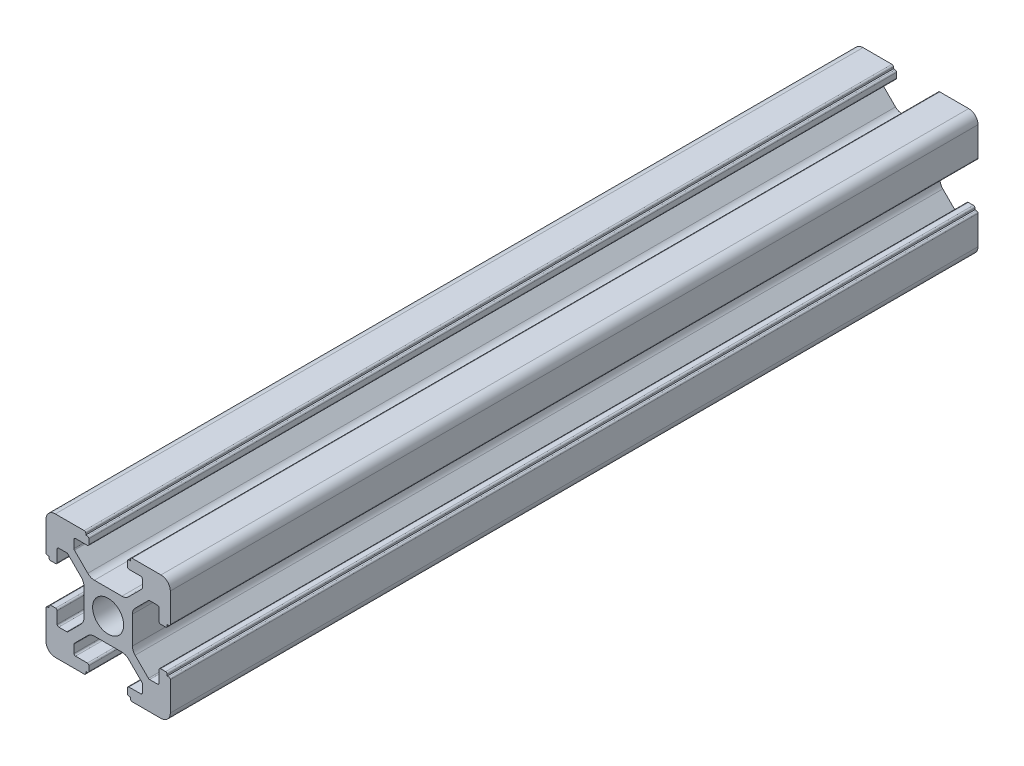
from build123d import *

# Parameters (mm, degrees)
SKETCH_1_R      = 2.5
EXTRUDE_1_DEPTH = 130


with BuildPart() as part:
    # 草图1 → 凸台-拉伸1 (new body)
    with BuildSketch(Plane.XY):
        with BuildLine():
            Line((-8.502261885, -10.002261885), (-3.85, -10.002261885))
            ThreePointArc((-3.85, -10.002261885), (-3.673223305, -9.929038581), (-3.6, -9.752261885))
            Line((-3.6, -9.752261885), (-3.6, -9.502261885))
            Line((-3.6, -9.502261885), (-3.35, -9.502261885))
            ThreePointArc((-3.35, -9.502261885), (-3.173223305, -9.429038581), (-3.1, -9.252261885))
            Line((-3.1, -9.252261885), (-3.1, -8.45))
            ThreePointArc((-3.1, -8.45), (-3.173223305, -8.273223305), (-3.35, -8.2))
            Line((-3.35, -8.2), (-5.25, -8.2))
            ThreePointArc((-5.25, -8.2), (-5.426776695, -8.126776695), (-5.5, -7.95))
            Line((-5.5, -7.95), (-5.5, -6.664213562))
            ThreePointArc((-5.5, -6.664213562), (-5.480969883, -6.568542704), (-5.426776695, -6.487436867))
            Line((-5.426776695, -6.487436867), (-3.278679656, -4.339339828))
            ThreePointArc((-3.278679656, -4.339339828), (-2.792044633, -4.014180701), (-2.218019485, -3.9))
            Line((-2.218019485, -3.9), (2.218019485, -3.9))
            ThreePointArc((2.218019485, -3.9), (2.792044633, -4.014180701), (3.278679656, -4.339339828))
            Line((3.278679656, -4.339339828), (5.426776695, -6.487436867))
            ThreePointArc((5.426776695, -6.487436867), (5.480969883, -6.568542704), (5.5, -6.664213562))
            Line((5.5, -6.664213562), (5.5, -7.95))
            ThreePointArc((5.5, -7.95), (5.426776695, -8.126776695), (5.25, -8.2))
            Line((5.25, -8.2), (3.35, -8.2))
            ThreePointArc((3.35, -8.2), (3.173223305, -8.273223305), (3.1, -8.45))
            Line((3.1, -8.45), (3.1, -9.252261885))
            ThreePointArc((3.1, -9.252261885), (3.173223305, -9.429038581), (3.35, -9.502261885))
            Line((3.35, -9.502261885), (3.6, -9.502261885))
            Line((3.6, -9.502261885), (3.6, -9.752261885))
            ThreePointArc((3.6, -9.752261885), (3.673223305, -9.929038581), (3.85, -10.002261885))
            Line((3.85, -10.002261885), (8.502261885, -10.002261885))
            ThreePointArc((8.502261885, -10.002261885), (9.562922057, -9.562922057), (10.002261885, -8.502261885))
            Line((10.002261885, -8.502261885), (10.002261885, -3.85))
            ThreePointArc((10.002261885, -3.85), (9.929038581, -3.673223305), (9.752261885, -3.6))
            Line((9.752261885, -3.6), (9.502261885, -3.6))
            Line((9.502261885, -3.6), (9.502261885, -3.35))
            ThreePointArc((9.502261885, -3.35), (9.429038581, -3.173223305), (9.252261885, -3.1))
            Line((9.252261885, -3.1), (8.45, -3.1))
            ThreePointArc((8.45, -3.1), (8.273223305, -3.173223305), (8.2, -3.35))
            Line((8.2, -3.35), (8.2, -5.25))
            ThreePointArc((8.2, -5.25), (8.126776695, -5.426776695), (7.95, -5.5))
            Line((7.95, -5.5), (6.664213562, -5.5))
            ThreePointArc((6.664213562, -5.5), (6.568542704, -5.480969883), (6.487436867, -5.426776695))
            Line((6.487436867, -5.426776695), (4.339339828, -3.278679656))
            ThreePointArc((4.339339828, -3.278679656), (4.014180701, -2.792044633), (3.9, -2.218019485))
            Line((3.9, -2.218019485), (3.9, 2.218019485))
            ThreePointArc((3.9, 2.218019485), (4.014180701, 2.792044633), (4.339339828, 3.278679656))
            Line((4.339339828, 3.278679656), (6.487436867, 5.426776695))
            ThreePointArc((6.487436867, 5.426776695), (6.568542704, 5.480969883), (6.664213562, 5.5))
            Line((6.664213562, 5.5), (7.95, 5.5))
            ThreePointArc((7.95, 5.5), (8.126776695, 5.426776695), (8.2, 5.25))
            Line((8.2, 5.25), (8.2, 3.35))
            ThreePointArc((8.2, 3.35), (8.273223305, 3.173223305), (8.45, 3.1))
            Line((8.45, 3.1), (9.252261885, 3.1))
            ThreePointArc((9.252261885, 3.1), (9.429038581, 3.173223305), (9.502261885, 3.35))
            Line((9.502261885, 3.35), (9.502261885, 3.6))
            Line((9.502261885, 3.6), (9.752261885, 3.6))
            ThreePointArc((9.752261885, 3.6), (9.929038581, 3.673223305), (10.002261885, 3.85))
            Line((10.002261885, 3.85), (10.002261885, 8.502261885))
            ThreePointArc((10.002261885, 8.502261885), (9.562922057, 9.562922057), (8.502261885, 10.002261885))
            Line((8.502261885, 10.002261885), (3.85, 10.002261885))
            ThreePointArc((3.85, 10.002261885), (3.673223305, 9.929038581), (3.6, 9.752261885))
            Line((3.6, 9.752261885), (3.6, 9.502261885))
            Line((3.6, 9.502261885), (3.35, 9.502261885))
            ThreePointArc((3.35, 9.502261885), (3.173223305, 9.429038581), (3.1, 9.252261885))
            Line((3.1, 9.252261885), (3.1, 8.45))
            ThreePointArc((3.1, 8.45), (3.173223305, 8.273223305), (3.35, 8.2))
            Line((3.35, 8.2), (5.25, 8.2))
            ThreePointArc((5.25, 8.2), (5.426776695, 8.126776695), (5.5, 7.95))
            Line((5.5, 7.95), (5.5, 6.664213562))
            ThreePointArc((5.5, 6.664213562), (5.480969883, 6.568542704), (5.426776695, 6.487436867))
            Line((5.426776695, 6.487436867), (3.278679656, 4.339339828))
            ThreePointArc((3.278679656, 4.339339828), (2.792044633, 4.014180701), (2.218019485, 3.9))
            Line((2.218019485, 3.9), (-2.218019485, 3.9))
            ThreePointArc((-2.218019485, 3.9), (-2.792044633, 4.014180701), (-3.278679656, 4.339339828))
            Line((-3.278679656, 4.339339828), (-5.426776695, 6.487436867))
            ThreePointArc((-5.426776695, 6.487436867), (-5.480969883, 6.568542704), (-5.5, 6.664213562))
            Line((-5.5, 6.664213562), (-5.5, 7.95))
            ThreePointArc((-5.5, 7.95), (-5.426776695, 8.126776695), (-5.25, 8.2))
            Line((-5.25, 8.2), (-3.35, 8.2))
            ThreePointArc((-3.35, 8.2), (-3.173223305, 8.273223305), (-3.1, 8.45))
            Line((-3.1, 8.45), (-3.1, 9.252261885))
            ThreePointArc((-3.1, 9.252261885), (-3.173223305, 9.429038581), (-3.35, 9.502261885))
            Line((-3.35, 9.502261885), (-3.6, 9.502261885))
            Line((-3.6, 9.502261885), (-3.6, 9.752261885))
            ThreePointArc((-3.6, 9.752261885), (-3.673223305, 9.929038581), (-3.85, 10.002261885))
            Line((-3.85, 10.002261885), (-8.502261885, 10.002261885))
            ThreePointArc((-8.502261885, 10.002261885), (-9.562922057, 9.562922057), (-10.002261885, 8.502261885))
            Line((-10.002261885, 8.502261885), (-10.002261885, 3.85))
            ThreePointArc((-10.002261885, 3.85), (-9.929038581, 3.673223305), (-9.752261885, 3.6))
            Line((-9.752261885, 3.6), (-9.502261885, 3.6))
            Line((-9.502261885, 3.6), (-9.502261885, 3.35))
            ThreePointArc((-9.502261885, 3.35), (-9.429038581, 3.173223305), (-9.252261885, 3.1))
            Line((-9.252261885, 3.1), (-8.45, 3.1))
            ThreePointArc((-8.45, 3.1), (-8.273223305, 3.173223305), (-8.2, 3.35))
            Line((-8.2, 3.35), (-8.2, 5.25))
            ThreePointArc((-8.2, 5.25), (-8.126776695, 5.426776695), (-7.95, 5.5))
            Line((-7.95, 5.5), (-6.664213562, 5.5))
            ThreePointArc((-6.664213562, 5.5), (-6.568542704, 5.480969883), (-6.487436867, 5.426776695))
            Line((-6.487436867, 5.426776695), (-4.339339828, 3.278679656))
            ThreePointArc((-4.339339828, 3.278679656), (-4.014180701, 2.792044633), (-3.9, 2.218019485))
            Line((-3.9, 2.218019485), (-3.9, -2.218019485))
            ThreePointArc((-3.9, -2.218019485), (-4.014180701, -2.792044633), (-4.339339828, -3.278679656))
            Line((-4.339339828, -3.278679656), (-6.487436867, -5.426776695))
            ThreePointArc((-6.487436867, -5.426776695), (-6.568542704, -5.480969883), (-6.664213562, -5.5))
            Line((-6.664213562, -5.5), (-7.95, -5.5))
            ThreePointArc((-7.95, -5.5), (-8.126776695, -5.426776695), (-8.2, -5.25))
            Line((-8.2, -5.25), (-8.2, -3.35))
            ThreePointArc((-8.2, -3.35), (-8.273223305, -3.173223305), (-8.45, -3.1))
            Line((-8.45, -3.1), (-9.252261885, -3.1))
            ThreePointArc((-9.252261885, -3.1), (-9.429038581, -3.173223305), (-9.502261885, -3.35))
            Line((-9.502261885, -3.35), (-9.502261885, -3.6))
            Line((-9.502261885, -3.6), (-9.752261885, -3.6))
            ThreePointArc((-9.752261885, -3.6), (-9.929038581, -3.673223305), (-10.002261885, -3.85))
            Line((-10.002261885, -3.85), (-10.002261885, -8.502261885))
            ThreePointArc((-10.002261885, -8.502261885), (-9.562922057, -9.562922057), (-8.502261885, -10.002261885))
        make_face()
        Circle(SKETCH_1_R, mode=Mode.SUBTRACT)
    extrude(amount=EXTRUDE_1_DEPTH)


solid = part.part
